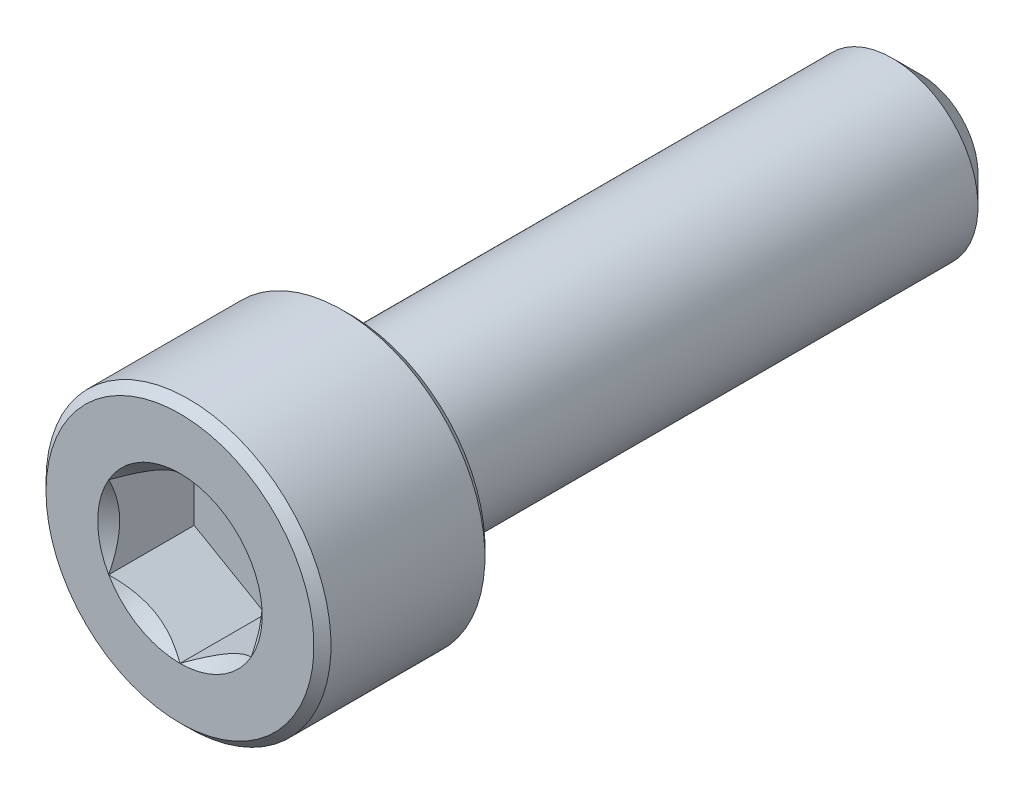
from build123d import *

# Parameters (mm, degrees)
CUT_EXTRUDE1_START = -3
CUT_EXTRUDE1_DEPTH = 3
SKETCH4_R          = 2.886751346
CUT_EXTRUDE2_DEPTH = 0.5
CUT_EXTRUDE2_TAPER = 45


with BuildPart() as part:
    # Sketch2 → Revolve1 (revolve)
    with BuildSketch(Plane(origin=(0, 0, 0), x_dir=(0, 0, -1), z_dir=(1, 0, 0))):
        Polygon((-12.7, 5), (-7.3, 5), (-7, 4.7), (-7, 3), (12, 3), (13, 2), (13, 0), (-13, 0), (-13, 4.7), align=None)
    revolve(axis=Axis((0, 0, -13), (0, 0, 1)))

    # Sketch3 → Cut-Extrude1 (cut)
    with BuildSketch(Plane.XY.offset(13).offset(CUT_EXTRUDE1_START)):
        Polygon((0, 2.886751346), (-2.5, 1.443375673), (-2.5, -1.443375673), (0, -2.886751346), (2.5, -1.443375673), (2.5, 1.443375673), align=None)
    extrude(amount=CUT_EXTRUDE1_DEPTH, mode=Mode.SUBTRACT)

    # Sketch4 → Cut-Extrude2 (cut)
    with BuildSketch(Plane.XY.offset(13)):
        Circle(SKETCH4_R)
    extrude(amount=-CUT_EXTRUDE2_DEPTH, taper=CUT_EXTRUDE2_TAPER, mode=Mode.SUBTRACT)


solid = part.part
